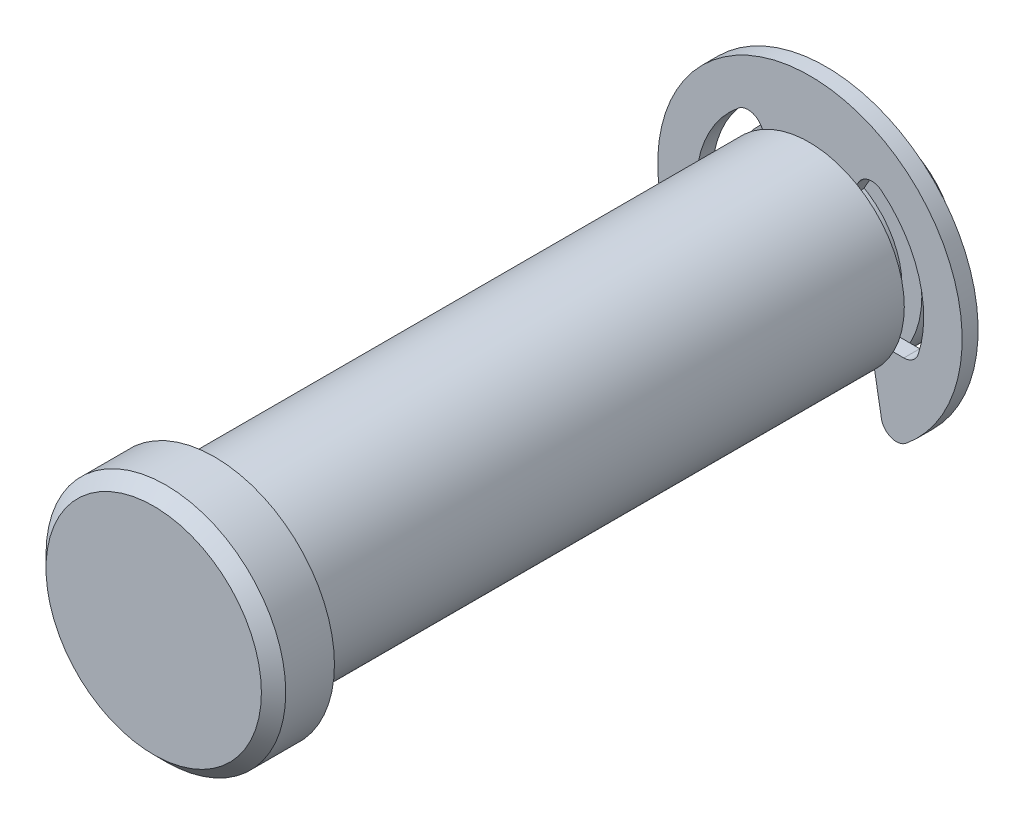
from build123d import *

# Parameters (mm, degrees)
SKETCH2_R      = 6.35
EXTRUDE1_DEPTH = 22.225
SKETCH3_W      = 1.1684
SKETCH3_H      = 1.3208
SKETCH8_R      = 8.001
EXTRUDE6_DEPTH = 4.064
CHAMFER2_SIZE  = 0.8128
SKETCH4_R      = 10.16
SKETCH4_R_2    = 5.0292
EXTRUDE2_DEPTH = 0.5334
EXTRUDE4_DEPTH = 23.225
EXTRUDE5_DEPTH = 1.0668
FILLET1_R      = 1.016
CHAMFER1_SIZE  = 1.27


with BuildPart() as part:
    # Sketch2 → Extrude1 (new body, symmetric)
    with BuildSketch(Plane.XY):
        Circle(SKETCH2_R)
    extrude(amount=EXTRUDE1_DEPTH, both=True)

    # Sketch3 → Cut-Revolve1 (revolve, cut)
    with BuildSketch(Plane(origin=(0, 0, 0), x_dir=(0, 0, -1), z_dir=(1, 0, 0))):
        with Locations((18.0467, 5.6896)):
            Rectangle(SKETCH3_W, SKETCH3_H)
    revolve(axis=Axis((0, 0, 22.225), (0, 0, -1)), mode=Mode.SUBTRACT)

    # Sketch8 → Extrude6 (add)
    with BuildSketch(Plane.XY.offset(22.225)):
        Circle(SKETCH8_R)
    extrude(amount=EXTRUDE6_DEPTH)

    # Chamfer2
    chamfer2_edges = [part.edges().sort_by_distance(p)[0] for p in [
        (-8.001, 0, 26.289),
    ]]
    chamfer(chamfer2_edges, length=CHAMFER2_SIZE)

    # Chamfer1
    chamfer1_edges = [part.edges().sort_by_distance(p)[0] for p in [
        (-6.35, 0, -22.225),
    ]]
    chamfer(chamfer1_edges, length=CHAMFER1_SIZE)


with BuildPart() as body_2:
    # Sketch4 → Extrude2 (new body, symmetric)
    with BuildSketch(Plane.XY.offset(-18.0467)):
        Circle(SKETCH4_R)
        Circle(SKETCH4_R_2, mode=Mode.SUBTRACT)
    extrude(amount=EXTRUDE2_DEPTH, both=True)

    # Sketch5 → Extrude4 (cut, through all)
    with BuildSketch(Plane.XY):
        with BuildLine():
            Line((-3.7973, 6.577116532), (0, 0))
            Line((0, 0), (3.7973, 6.577116532))
            ThreePointArc((3.7973, 6.577116532), (7.210736044, 2.383953619), (6.969398985, -3.01752))
            Line((6.969398985, -3.01752), (4.02336, -3.01752))
            Line((4.02336, -3.01752), (5.04618595, -8.818254213))
            ThreePointArc((5.04618595, -8.818254213), (0, -10.16), (-5.04618595, -8.818254213))
            Line((-5.04618595, -8.818254213), (-4.02336, -3.01752))
            Line((-4.02336, -3.01752), (-6.969398985, -3.01752))
            ThreePointArc((-6.969398985, -3.01752), (-7.210736044, 2.383953619), (-3.7973, 6.577116532))
        make_face()
    extrude(amount=-EXTRUDE4_DEPTH, mode=Mode.SUBTRACT)

    # Sketch6 → Extrude5 (add)
    with BuildSketch(Plane.XY.offset(-17.5133)):
        with BuildLine():
            Line((-2.5146, 4.355414961), (2.5146, 4.355414961))
            ThreePointArc((2.5146, 4.355414961), (0, 5.0292), (-2.5146, 4.355414961))
        make_face()
    extrude(amount=-EXTRUDE5_DEPTH)

    # Fillet1
    fillet1_edges = [body_2.edges().sort_by_distance(p)[0] for p in [
        (3.7973, 6.577116532, -18.0467),
        (5.04618595, -8.818254213, -18.0467),
        (-6.969398985, -3.01752, -18.0467),
        (6.969398985, -3.01752, -18.0467),
        (-5.04618595, -8.818254213, -18.0467),
        (-3.7973, 6.577116532, -18.0467),
    ]]
    fillet(fillet1_edges, radius=FILLET1_R)


solid = Compound([part.part, body_2.part])
